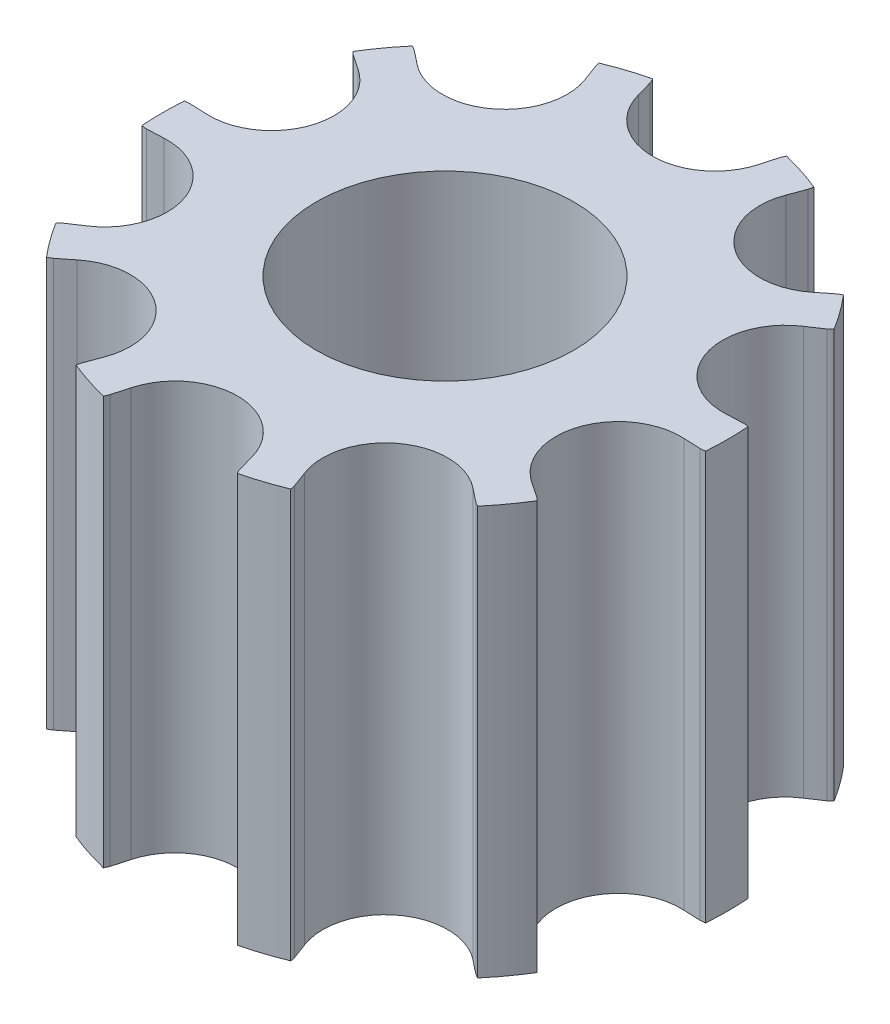
from build123d import *

# Parameters (mm, degrees)
SKETCH1_R          = 4.393648446
TOOTHOD_DEPTH      = 3.4925
TOOTHPROFILE_DEPTH = 8.127822218
TOOTHPATTERN_COUNT = 10
BORE_DEPTH         = 10.035238042
BORE_DEPTH_BACK    = 10.035238042
SKETCH7_R          = 2
CUT_EXTRUDE1_START = 3.175
SKETCH11_R         = 5.536648446
CUT_EXTRUDE1_DEPTH = 6.860238042
CUT_EXTRUDE2_START = -3.175
SKETCH11_2_R       = 5.536648446
CUT_EXTRUDE2_DEPTH = 6.860238042


with BuildPart() as part:
    # Sketch1 → ToothOD (new, symmetric)
    with BuildSketch(Plane(origin=(0, 0, 0), x_dir=(1, 0, 0), z_dir=(0, 1, 0))):
        Circle(SKETCH1_R)
    extrude(amount=TOOTHOD_DEPTH, both=True)

    # Sketch2 → ToothProfile (cut, symmetric)
    with BuildSketch(Plane(origin=(0, 0, 0), x_dir=(1, 0, 0), z_dir=(0, 1, 0))):
        with BuildLine():
            ThreePointArc((-0.937033068, 3.943710441), (-0.590385173, 3.425535831), (0, 3.225248446))
            ThreePointArc((0, 3.225248446), (0.590385173, 3.425535831), (0.937033068, 3.943710441))
            ThreePointArc((0.937033068, 3.943710441), (0.971699064, 4.069821903), (1.007805813, 4.195528446))
            ThreePointArc((1.007805813, 4.195528446), (1.021661234, 4.233200647), (1.040426249, 4.268683624))
            ThreePointArc((1.040426249, 4.268683624), (0, 4.393648446), (-1.040426249, 4.268683624))
            ThreePointArc((-1.040426249, 4.268683624), (-1.021661234, 4.233200647), (-1.007805813, 4.195528446))
            ThreePointArc((-1.007805813, 4.195528446), (-0.971699064, 4.069821903), (-0.937033068, 3.943710441))
        make_face()
    toothprofile = extrude(amount=TOOTHPROFILE_DEPTH, both=True, mode=Mode.SUBTRACT)

    # ToothPattern: ToothProfile ×10 about axis
    toothpattern_axis = Axis((0, 3.4925, 0), (0, -1, 0))
    for i in range(1, TOOTHPATTERN_COUNT):
        add(toothprofile.rotate(toothpattern_axis, i * 360 / TOOTHPATTERN_COUNT), mode=Mode.SUBTRACT)

    # Sketch4 → Flange (revolve)
    with BuildSketch(Plane.XY):
        with BuildLine():
            Line((0, -3.4925), (4.647648446, -3.4925))
            ThreePointArc((4.647648446, -3.4925), (4.839929254, -3.531494589), (5.028648446, -3.585137424))
            ThreePointArc((5.028648446, -3.585137424), (5.304690043, -3.90309066), (5.536648446, -4.2545))
            Line((5.536648446, -4.2545), (5.536648446, -4.5085))
            Line((5.536648446, -4.5085), (0, -4.5085))
            Line((0, -4.5085), (0, -3.4925))
        make_face()
        with BuildLine():
            Line((5.536648446, 4.5085), (5.536648446, 4.2545))
            ThreePointArc((5.536648446, 4.2545), (5.304690043, 3.90309066), (5.028648446, 3.585137424))
            ThreePointArc((5.028648446, 3.585137424), (4.839929254, 3.531494589), (4.647648446, 3.4925))
            Line((4.647648446, 3.4925), (0, 3.4925))
            Line((0, 3.4925), (0, 4.5085))
            Line((0, 4.5085), (5.536648446, 4.5085))
        make_face()
    revolve(axis=Axis((0, 8.73125, 0), (0, -1, 0)))

    # Sketch7 → Bore (cut, two sides: drawn at the far end of the back side and taken through both)
    with BuildSketch(Plane.XZ.offset(-BORE_DEPTH_BACK)):
        Circle(SKETCH7_R)
    extrude(amount=BORE_DEPTH + BORE_DEPTH_BACK, mode=Mode.SUBTRACT)

    # Sketch11 → Cut-Extrude1 (cut, through all)
    with BuildSketch(Plane(origin=(0, 0, 0), x_dir=(1, 0, 0), z_dir=(0, 1, 0)).offset(CUT_EXTRUDE1_START)):
        Circle(SKETCH11_R)
    extrude(amount=CUT_EXTRUDE1_DEPTH, mode=Mode.SUBTRACT)

    # Sketch11_2 → Cut-Extrude2 (cut, through all)
    with BuildSketch(Plane(origin=(0, 0, 0), x_dir=(1, 0, 0), z_dir=(0, 1, 0)).offset(CUT_EXTRUDE2_START)):
        Circle(SKETCH11_2_R)
    extrude(amount=-CUT_EXTRUDE2_DEPTH, mode=Mode.SUBTRACT)


solid = part.part
